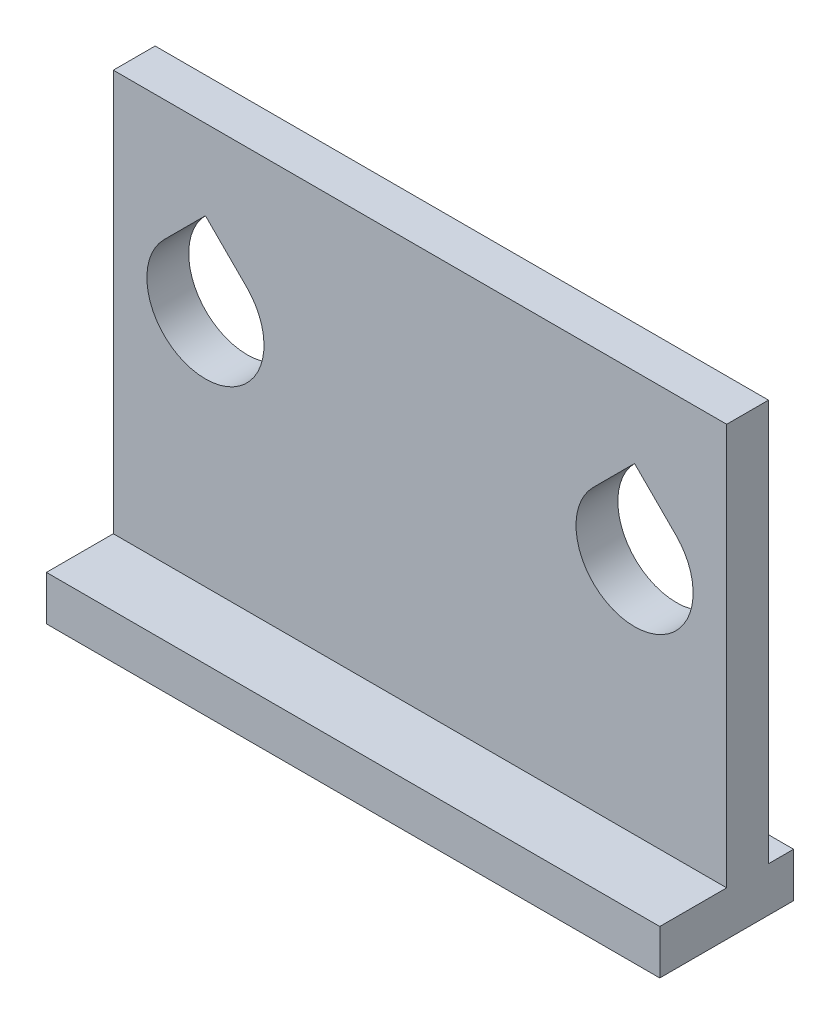
from build123d import *

# Parameters (mm, degrees)
SKETCH1_W                = 110
SKETCH1_H                = 80
BOSS_EXTRUDE1_DEPTH      = 7.5
SKETCH3_W                = 110
SKETCH3_H                = 8
BOSS_EXTRUDE2_DEPTH      = 12
BOSS_EXTRUDE2_DEPTH_BACK = 12


with BuildPart() as part:
    # Sketch1 → Boss-Extrude1 (new body)
    with BuildSketch(Plane.XY):
        with Locations((0, 40)):
            Rectangle(SKETCH1_W, SKETCH1_H)
        with BuildLine():
            ThreePointArc((-27.981, 50.8), (-42.49917604, 41.099264909), (-45.905621202, 58.224621202))
            Line((-45.905621202, 58.224621202), (-38.481, 65.649242405))
            Line((-38.481, 65.649242405), (-31.056378798, 58.224621202))
            ThreePointArc((-31.056378798, 58.224621202), (-28.780264909, 54.81817604), (-27.981, 50.8))
        make_face(mode=Mode.SUBTRACT)
        with BuildLine():
            ThreePointArc((27.981, 50.8), (28.780264909, 54.81817604), (31.056378798, 58.224621202))
            Line((31.056378798, 58.224621202), (38.481, 65.649242405))
            Line((38.481, 65.649242405), (45.905621202, 58.224621202))
            ThreePointArc((45.905621202, 58.224621202), (48.181735091, 54.81817604), (48.981, 50.8))
            ThreePointArc((48.981, 50.8), (38.481, 40.3), (27.981, 50.8))
        make_face(mode=Mode.SUBTRACT)
    extrude(amount=BOSS_EXTRUDE1_DEPTH)

    # Sketch3 → Boss-Extrude2 (add, two sides)
    with BuildSketch(Plane.XY.offset(7.5)) as boss_extrude2_sk:
        with Locations((0, 4)):
            Rectangle(SKETCH3_W, SKETCH3_H)
    extrude(amount=BOSS_EXTRUDE2_DEPTH)
    extrude(boss_extrude2_sk.sketch, amount=-BOSS_EXTRUDE2_DEPTH_BACK)


solid = part.part
